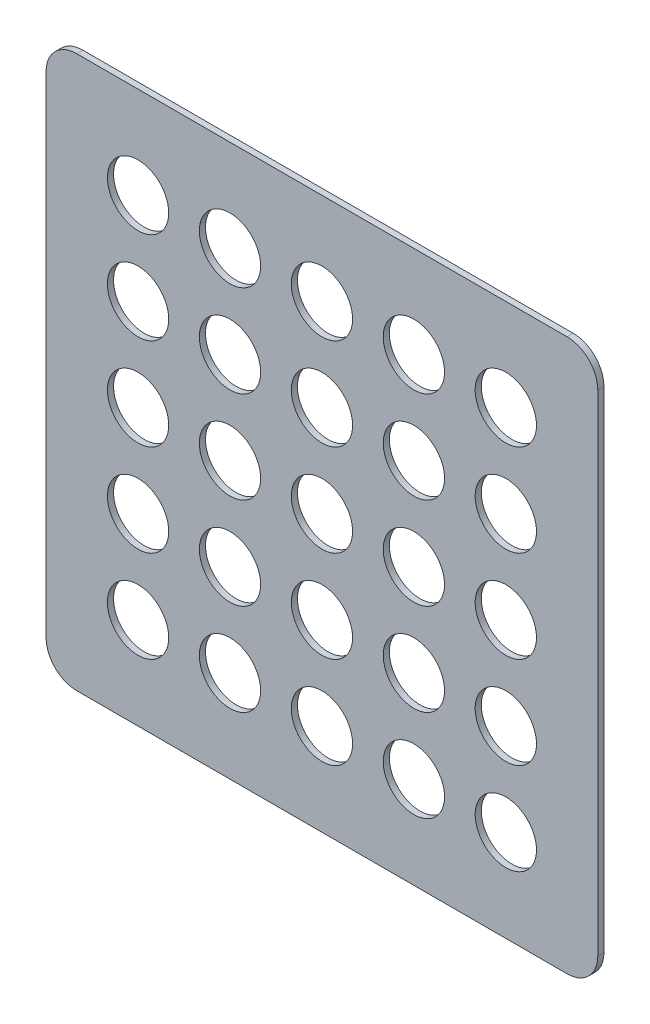
from build123d import *

# Parameters (mm, degrees)
SKETCH1_W           = 4.5
SKETCH1_H           = 4.5
BOSS_EXTRUDE1_DEPTH = 0.05
FILLET1_R           = 0.25
SKETCH2_R           = 0.25
CUT_EXTRUDE1_DEPTH  = 0.05


with BuildPart() as part:
    # Sketch1 → Boss-Extrude1 (new body)
    with BuildSketch(Plane.XY):
        Rectangle(SKETCH1_W, SKETCH1_H)
    extrude(amount=BOSS_EXTRUDE1_DEPTH)

    # Fillet1
    fillet1_edges = [part.edges().sort_by_distance(p)[0] for p in [
        (2.25, -2.25, 0.025),
        (-2.25, -2.25, 0.025),
        (-2.25, 2.25, 0.025),
        (2.25, 2.25, 0.025),
    ]]
    fillet(fillet1_edges, radius=FILLET1_R)

    # Sketch2 → Cut-Extrude1 (cut)
    with BuildSketch(Plane.XY.offset(0.05)):
        with Locations((-1.5, 0)):
            Circle(SKETCH2_R)
        with Locations((-1.5, 0.75)):
            Circle(SKETCH2_R)
        with Locations((-1.5, 1.5)):
            Circle(SKETCH2_R)
        with Locations((-0.75, 1.5)):
            Circle(SKETCH2_R)
        with Locations((0, 1.5)):
            Circle(SKETCH2_R)
        with Locations((0.75, 1.5)):
            Circle(SKETCH2_R)
        with Locations((1.5, 1.5)):
            Circle(SKETCH2_R)
        with Locations((1.5, 0.75)):
            Circle(SKETCH2_R)
        with Locations((0.75, 0.75)):
            Circle(SKETCH2_R)
        with Locations((0, 0.75)):
            Circle(SKETCH2_R)
        with Locations((-0.75, 0.75)):
            Circle(SKETCH2_R)
        with Locations((-0.75, 0)):
            Circle(SKETCH2_R)
        Circle(SKETCH2_R)
        with Locations((0.75, 0)):
            Circle(SKETCH2_R)
        with Locations((1.5, 0)):
            Circle(SKETCH2_R)
        with Locations((1.5, -0.75)):
            Circle(SKETCH2_R)
        with Locations((1.5, -1.5)):
            Circle(SKETCH2_R)
        with Locations((0.75, -1.5)):
            Circle(SKETCH2_R)
        with Locations((0.75, -0.75)):
            Circle(SKETCH2_R)
        with Locations((0, -1.5)):
            Circle(SKETCH2_R)
        with Locations((0, -0.75)):
            Circle(SKETCH2_R)
        with Locations((-0.75, -0.75)):
            Circle(SKETCH2_R)
        with Locations((-0.75, -1.5)):
            Circle(SKETCH2_R)
        with Locations((-1.5, -1.5)):
            Circle(SKETCH2_R)
        with Locations((-1.5, -0.75)):
            Circle(SKETCH2_R)
    extrude(amount=-CUT_EXTRUDE1_DEPTH, mode=Mode.SUBTRACT)


solid = part.part
